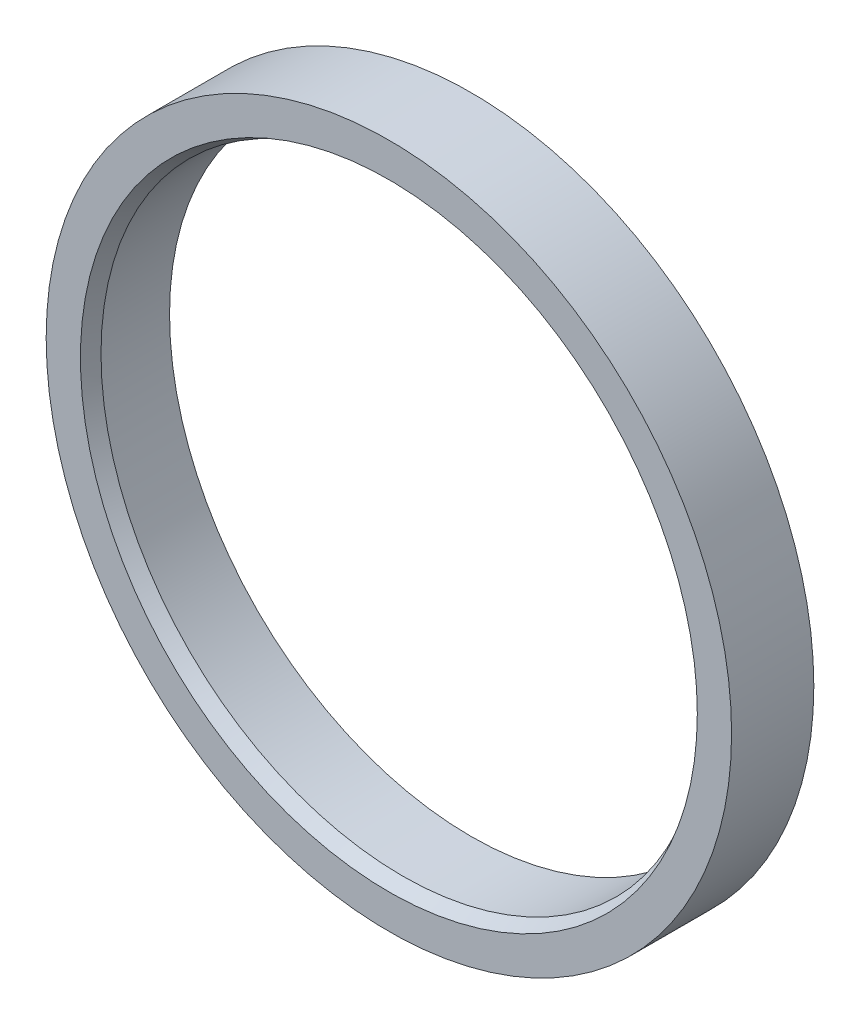
from build123d import *


with BuildPart() as part:
    # Sketch2 → Revolve1 (revolve)
    with BuildSketch(Plane(origin=(0, 0, 0), x_dir=(0, 0, -1), z_dir=(1, 0, 0))):
        Polygon((0, 71.4375), (3.175, 69.85), (19.05, 69.85), (19.05, 72.23125), (9.525, 72.23125), (9.525, 76.2), (19.05, 76.2), (19.05, 79.375), (0, 79.375), align=None)
    revolve(axis=Axis((0, 0, 0), (0, 0, -1)))


solid = part.part
